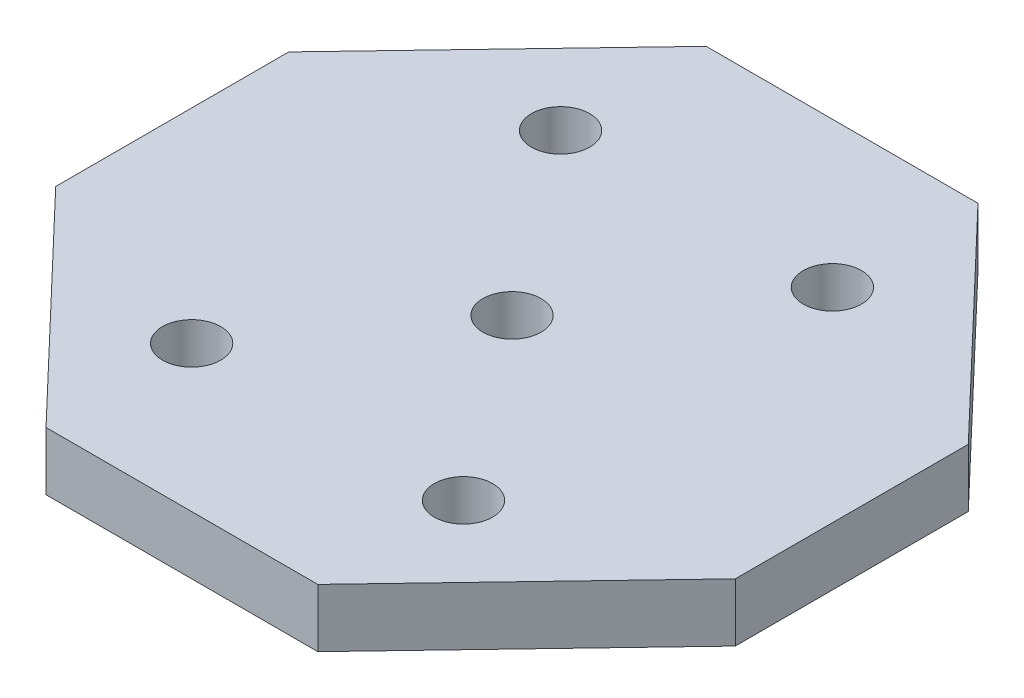
from build123d import *

# Parameters (mm, degrees)
SKETCH1_R           = 1.5
BOSS_EXTRUDE1_DEPTH = 1.5


with BuildPart() as part:
    # Sketch1 → Boss-Extrude1 (new body, symmetric)
    with BuildSketch(Plane(origin=(0, 0, 0), x_dir=(1, 0, 0), z_dir=(0, 1, 0))):
        with BuildLine():
            Line((1.5, 0), (17.5, 0))
            Line((17.5, 0), (17.5, 6))
            Line((17.5, 6), (7, 17))
            Line((7, 17), (0, 17))
            Line((0, 17), (-7, 17))
            Line((-7, 17), (-17.5, 6))
            Line((-17.5, 6), (-17.5, 0))
            Line((-17.5, 0), (-1.5, 0))
            ThreePointArc((-1.5, 0), (0, 1.5), (1.5, 0))
        make_face()
        with Locations((-7, 9.5)):
            Circle(SKETCH1_R, mode=Mode.SUBTRACT)
        with Locations((7, 9.5)):
            Circle(SKETCH1_R, mode=Mode.SUBTRACT)
        with BuildLine():
            Line((7, -17), (17.5, -6))
            Line((17.5, -6), (17.5, 0))
            Line((17.5, 0), (1.5, 0))
            ThreePointArc((1.5, 0), (0, -1.5), (-1.5, 0))
            Line((-1.5, 0), (-17.5, 0))
            Line((-17.5, 0), (-17.5, -6))
            Line((-17.5, -6), (-7, -17))
            Line((-7, -17), (0, -17))
            Line((0, -17), (7, -17))
        make_face()
        with Locations((-7, -9.5)):
            Circle(SKETCH1_R, mode=Mode.SUBTRACT)
        with Locations((7, -9.5)):
            Circle(SKETCH1_R, mode=Mode.SUBTRACT)
    extrude(amount=BOSS_EXTRUDE1_DEPTH, both=True)


solid = part.part
